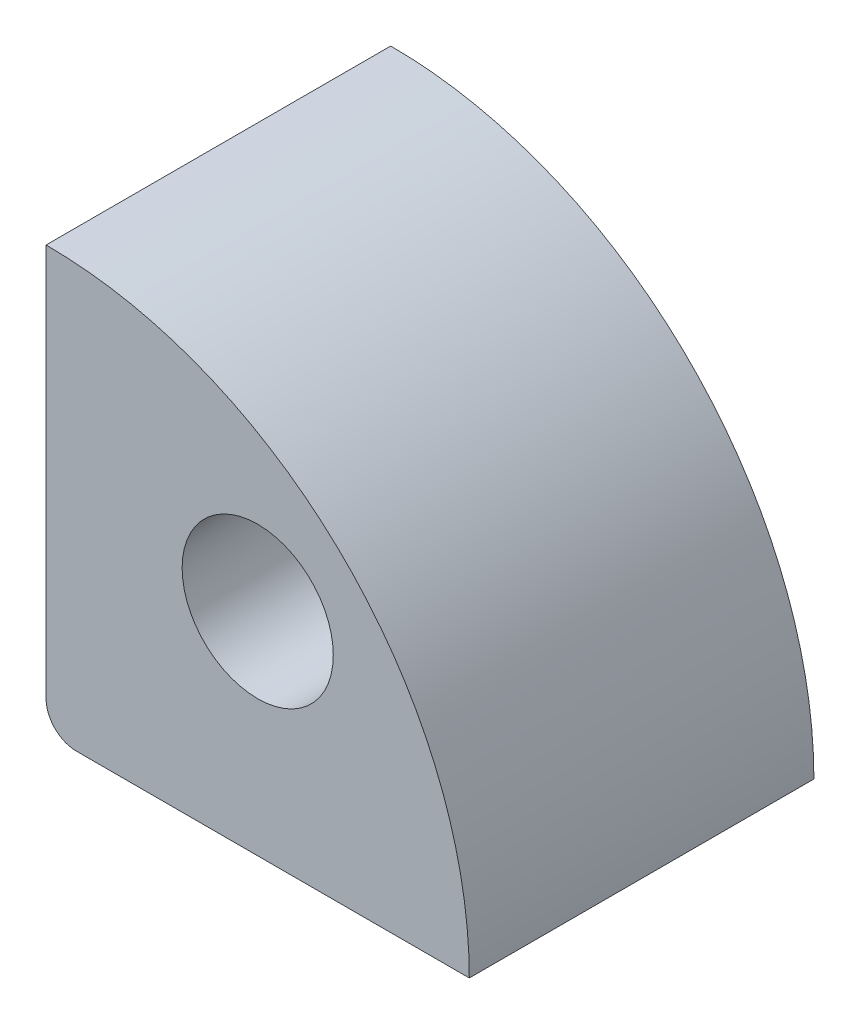
from build123d import *

# Parameters (mm, degrees)
P_IDAT_VYSUNUT_M1_DEPTH  = 5.7
SKICA2_R                 = 1.25
ODEBRAT_VYSUNUT_M1_DEPTH = 6.7
ZAOBLIT1_R               = 0.5


with BuildPart() as part:
    # Skica1 → Přidat vysunutím1 (new body)
    with BuildSketch(Plane.XY):
        with BuildLine():
            Line((0, 0), (7, 0))
            ThreePointArc((7, 0), (4.949747468, 4.949747468), (0, 7))
            Line((0, 7), (0, 0))
        make_face()
    extrude(amount=P_IDAT_VYSUNUT_M1_DEPTH)

    # Skica2 → Odebrat vysunutím1 (cut, through all)
    with BuildSketch(Plane.XY.offset(5.7)):
        with Locations((3.500178567, 3.500178567)):
            Circle(SKICA2_R)
    extrude(amount=-ODEBRAT_VYSUNUT_M1_DEPTH, mode=Mode.SUBTRACT)

    # Zaoblit1
    zaoblit1_edges = [part.edges().sort_by_distance(p)[0] for p in [
        (0, 0, 2.85),
    ]]
    fillet(zaoblit1_edges, radius=ZAOBLIT1_R)


solid = part.part
